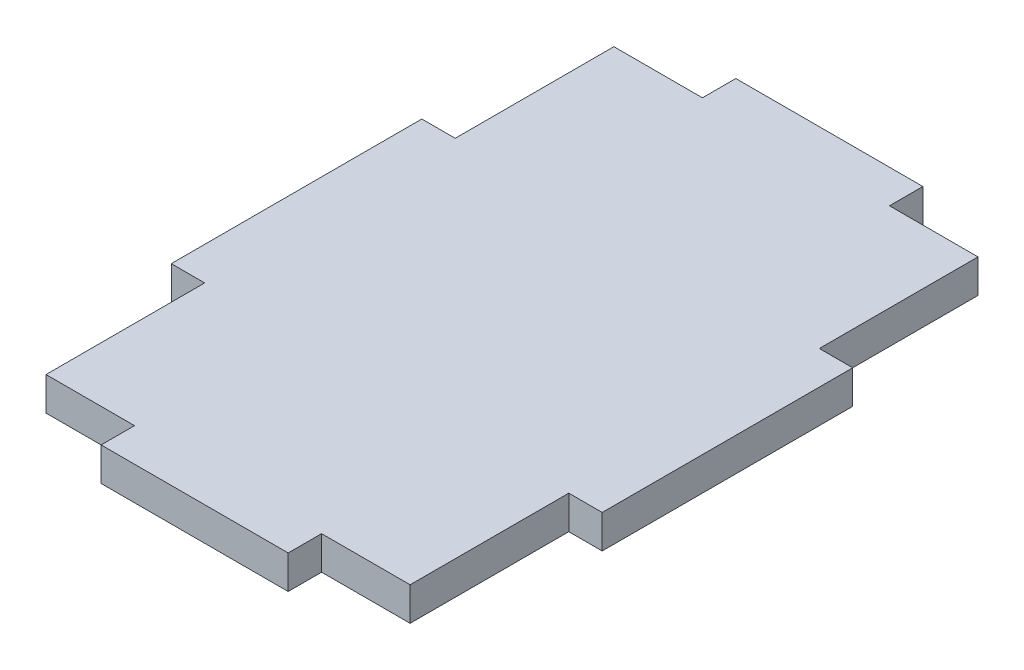
from build123d import *

# Parameters (mm, degrees)
BOSS_EXTRUDE1_DEPTH = 5


with BuildPart() as part:
    # Sketch2 → Boss-Extrude1 (new body)
    with BuildSketch(Plane(origin=(0, 0, 0), x_dir=(1, 0, 0), z_dir=(0, 1, 0))):
        Polygon((-27.25, 18.75), (-32.25, 18.75), (-32.25, -18.75), (-27.25, -18.75), (-27.25, -42.5), (-14, -42.5), (-14, -47.5), (14, -47.5), (14, -42.5), (27.25, -42.5), (27.25, -18.75), (32.25, -18.75), (32.25, 18.75), (27.25, 18.75), (27.25, 42.5), (14, 42.5), (14, 47.5), (-14, 47.5), (-14, 42.5), (-27.25, 42.5), align=None)
    extrude(amount=BOSS_EXTRUDE1_DEPTH)


solid = part.part
